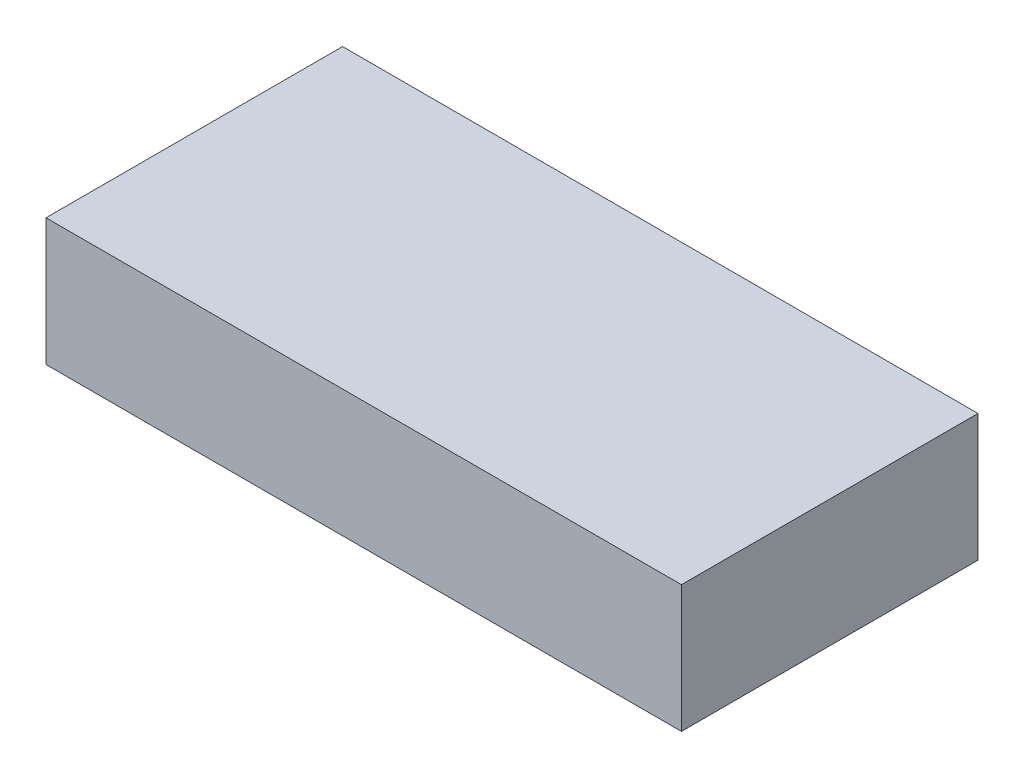
from build123d import *

# Parameters (mm, degrees)
SKETCH2_W           = 190.5
SKETCH2_H           = 88.9
BOSS_EXTRUDE1_DEPTH = 38.1


with BuildPart() as part:
    # Sketch2 → Boss-Extrude1 (new body)
    with BuildSketch(Plane(origin=(0, 0, 0), x_dir=(1, 0, 0), z_dir=(0, 1, 0))):
        with Locations((95.25, 44.45)):
            Rectangle(SKETCH2_W, SKETCH2_H)
    extrude(amount=BOSS_EXTRUDE1_DEPTH)


solid = part.part
